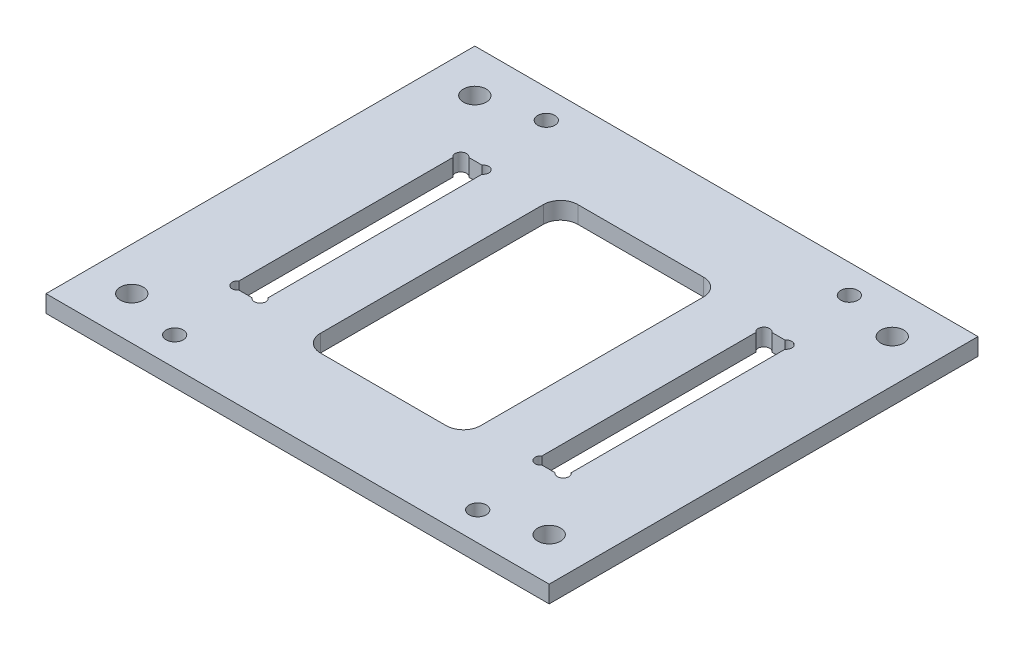
from build123d import *

# Parameters (mm, degrees)
SKETCH_1_W          = 88
SKETCH_1_H          = 75
EXTRUDE_1_DEPTH     = 3
SKETCH_2_R          = 1.5
SKETCH_2_R_2        = 1
SKETCH_2_W          = 5.1
SKETCH_2_H          = 40.2
SKETCH_2_R_3        = 2
SKETCH_2_W_2        = 28
SKETCH_2_H_2        = 45
CUT_EXTRUDE_1_DEPTH = 3
FILLET_1_R          = 3


with BuildPart() as part:
    # ｽｹｯﾁ1 → ﾎﾞｽ - 押し出し1 (new body)
    with BuildSketch(Plane(origin=(0, 0, 0), x_dir=(1, 0, 0), z_dir=(0, 1, 0))):
        Rectangle(SKETCH_1_W, SKETCH_1_H)
    extrude(amount=EXTRUDE_1_DEPTH)

    # ｽｹｯﾁ2 → ｶｯﾄ - 押し出し1 (cut)
    with BuildSketch(Plane(origin=(0, 3, 0), x_dir=(1, 0, 0), z_dir=(0, 1, 0))):
        with Locations((-26.5, 32.5)):
            Circle(SKETCH_2_R)
        with Locations((26.5, 32.5)):
            Circle(SKETCH_2_R)
        with Locations((-28.45, -19.5)):
            Circle(SKETCH_2_R_2)
        with Locations((-24.55, -19.5)):
            Circle(SKETCH_2_R_2)
        with Locations((-26.5, 0)):
            Rectangle(SKETCH_2_W, SKETCH_2_H)
        with Locations((-28.45, 19.5)):
            Circle(SKETCH_2_R_2)
        with Locations((-24.55, 19.5)):
            Circle(SKETCH_2_R_2)
        with Locations((26.5, 0)):
            Rectangle(SKETCH_2_W, SKETCH_2_H)
        with Locations((24.55, 19.5)):
            Circle(SKETCH_2_R_2)
        with Locations((28.45, 19.5)):
            Circle(SKETCH_2_R_2)
        with Locations((24.55, -19.5)):
            Circle(SKETCH_2_R_2)
        with Locations((28.45, -19.5)):
            Circle(SKETCH_2_R_2)
        with Locations((-26.5, -32.5)):
            Circle(SKETCH_2_R)
        with Locations((26.5, -32.5)):
            Circle(SKETCH_2_R)
        with Locations((-36.5, -30)):
            Circle(SKETCH_2_R_3)
        with Locations((-36.5, 30)):
            Circle(SKETCH_2_R_3)
        with Locations((36.5, 30)):
            Circle(SKETCH_2_R_3)
        with Locations((36.5, -30)):
            Circle(SKETCH_2_R_3)
        Rectangle(SKETCH_2_W_2, SKETCH_2_H_2)
    extrude(amount=-CUT_EXTRUDE_1_DEPTH, mode=Mode.SUBTRACT)

    # ﾌｨﾚｯﾄ1
    fillet_1_edges = [part.edges().sort_by_distance(p)[0] for p in [
        (-14, 1.5, -22.5),
        (14, 1.5, -22.5),
        (14, 1.5, 22.5),
        (-14, 1.5, 22.5),
    ]]
    fillet(fillet_1_edges, radius=FILLET_1_R)


solid = part.part
